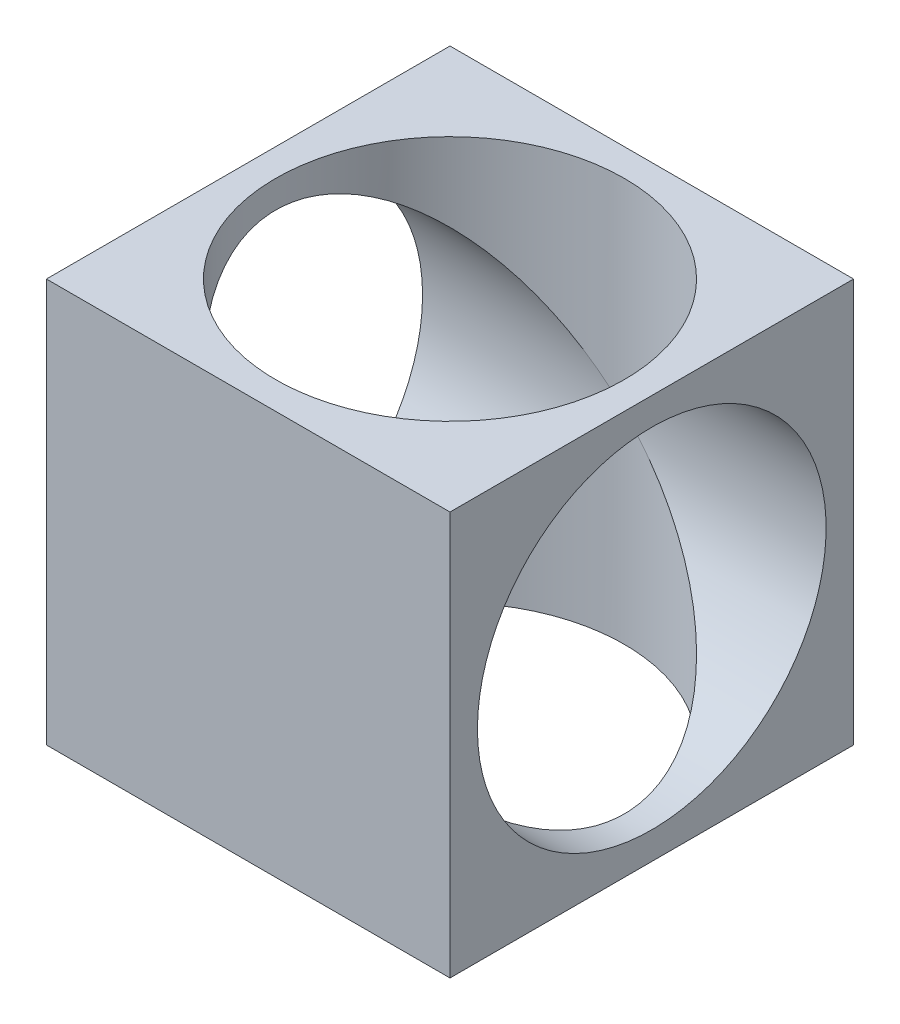
from build123d import *

# Parameters (mm, degrees)
SKETCH2_W               = 31.75
SKETCH2_H               = 31.75
BOSS_EXTRUDE1_DEPTH     = 31.75
SKETCH3_R               = 13.716
CUT_EXTRUDE1_DEPTH      = 1
CUT_EXTRUDE1_DEPTH_BACK = 32.75
SKETCH4_R               = 13.716
CUT_EXTRUDE2_DEPTH      = 1
CUT_EXTRUDE2_DEPTH_BACK = 32.75


with BuildPart() as part:
    # Sketch2 → Boss-Extrude1 (new body)
    with BuildSketch(Plane(origin=(0, 0, 0), x_dir=(1, 0, 0), z_dir=(0, 1, 0))):
        Rectangle(SKETCH2_W, SKETCH2_H)
    extrude(amount=BOSS_EXTRUDE1_DEPTH)

    # Sketch3 → Cut-Extrude1 (cut, two sides)
    with BuildSketch(Plane(origin=(0, 31.75, 0), x_dir=(1, 0, 0), z_dir=(0, 1, 0))) as cut_extrude1_sk:
        Circle(SKETCH3_R)
    extrude(amount=CUT_EXTRUDE1_DEPTH, mode=Mode.SUBTRACT)
    extrude(cut_extrude1_sk.sketch, amount=-CUT_EXTRUDE1_DEPTH_BACK, mode=Mode.SUBTRACT)

    # Sketch4 → Cut-Extrude2 (cut, two sides)
    with BuildSketch(Plane.ZY.offset(15.875)) as cut_extrude2_sk:
        with Locations((0, 15.875)):
            Circle(SKETCH4_R)
    extrude(amount=CUT_EXTRUDE2_DEPTH, mode=Mode.SUBTRACT)
    extrude(cut_extrude2_sk.sketch, amount=-CUT_EXTRUDE2_DEPTH_BACK, mode=Mode.SUBTRACT)


solid = part.part
